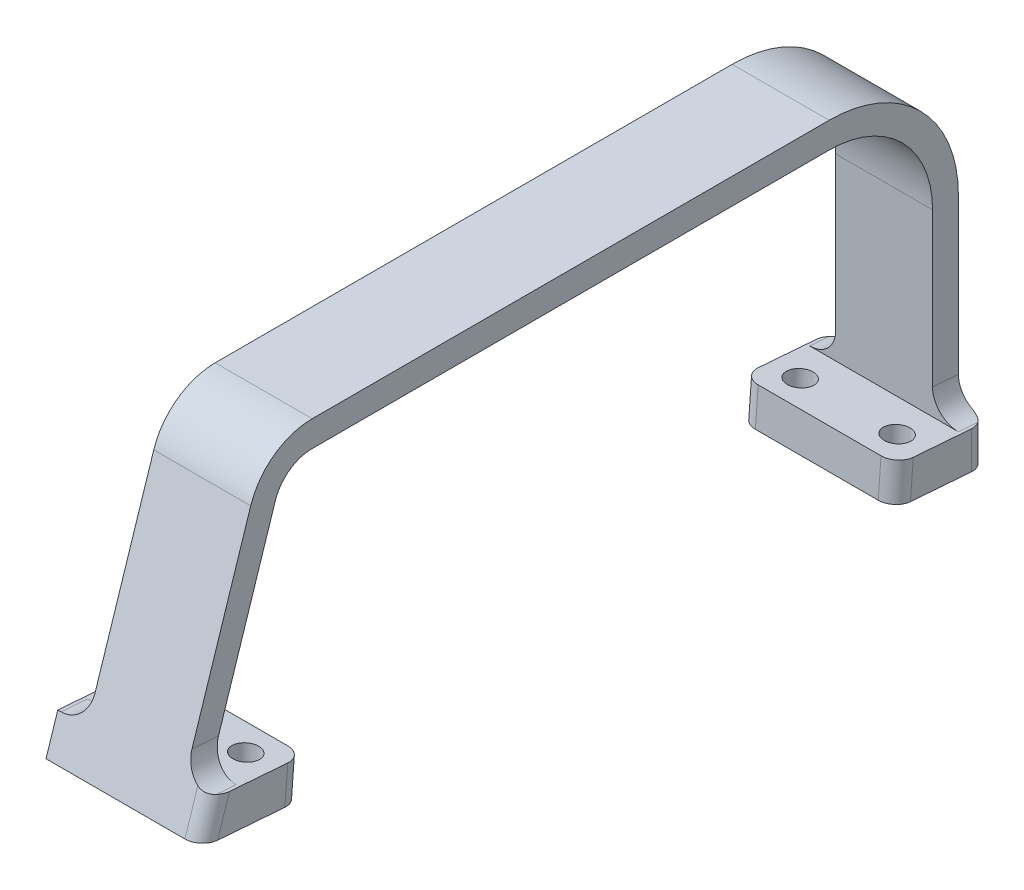
from build123d import *

# Parameters (mm, degrees)
BOSS_EXTRUDE1_DEPTH = 7.5
BOSS_EXTRUDE3_DEPTH = 12
FILLET1_R           = 2.5
FILLET2_R           = 4
CUT_EXTRUDE1_REACH  = 333.875
SKETCH5_R           = 2.0000000000001186
SKETCH5_R_2         = 2.0000000000001266
SKETCH5_R_3         = 2.0000000000001346


with BuildPart() as part:
    # Sketch1 → Boss-Extrude1 (new, symmetric)
    with BuildSketch(Plane(origin=(249.7714193313032, 90.19789758644944, 68.85838392138058), x_dir=(-1.36e-15, 0, -1), z_dir=(1, 1.23e-15, -1.36e-15))):
        with BuildLine():
            Line((276.40733700705005, 27.058032303601674), (280.40733700705005, 26.750876980739832))
            Line((280.40733700705005, 26.750876980739832), (280.40733700705005, 54.805859741005065))
            ThreePointArc((280.40733700705005, 54.80585974100506), (274.549472630781, 68.947995364736), (260.40733700705005, 74.80585974100505))
            Line((260.40733700705005, 74.80585974100507), (180.40733700705002, 74.80585974100505))
            ThreePointArc((180.40733700705002, 74.80585974100504), (174.52666621732683, 72.89398134388023), (170.89462091629855, 67.88940195358433))
            Line((170.89462091629855, 67.88940195358433), (158.7191888589005, 30.328239997775782))
            Line((158.7191888589005, 30.32823999777578), (162.8219643315265, 30.01319266654476))
            Line((162.8219643315265, 30.013192666544757), (174.69970735259915, 66.65598506855262))
            ThreePointArc((174.69970735259915, 66.65598506855262), (176.8789345332161, 69.65873270273018), (180.40733700705002, 70.80585974100507))
            Line((180.40733700705002, 70.80585974100505), (260.40733700705005, 70.80585974100507))
            ThreePointArc((260.40733700705005, 70.80585974100507), (271.7210455060348, 66.1195682399898), (276.40733700705005, 54.80585974100506))
            Line((276.40733700705005, 54.80585974100506), (276.40733700705005, 27.058032303601674))
        make_face()
    extrude(amount=BOSS_EXTRUDE1_DEPTH, both=True)

    # Sketch1_4 → Boss-Extrude3 (add, symmetric)
    with BuildSketch(Plane(origin=(249.7714193313032, 90.19789758644944, 68.85838392138058), x_dir=(-1.36e-15, 0, -1), z_dir=(1, 1.23e-15, -1.36e-15))):
        Polygon((174.61655820891, 34.87442718512688), (164.64591108515557, 35.64006151923646), (162.8219643315265, 30.01319266654476), (174.17631846679706, 29.14130508896809), align=None)
        Polygon((164.64591108515557, 35.64006151923646), (160.5431356125297, 35.95510885046747), (158.7191888589005, 30.328239997775782), (162.8219643315265, 30.01319266654476), align=None)
        Polygon((276.40733700705005, 21.291104712411546), (280.40733700705005, 20.983949389549675), (280.40733700705005, 26.750876980739832), (276.40733700705005, 27.058032303601674), align=None)
        Polygon((265.9964501411826, 22.090544541552422), (276.40733700705005, 21.291104712411546), (276.40733700705005, 27.058032303601674), (266.4366898832956, 27.823666637711245), align=None)
    extrude(amount=BOSS_EXTRUDE3_DEPTH, both=True)

    # Fillet1
    fillet1_edges = [part.edges().sort_by_distance(p)[0] for p in [
        (237.77141933130292, 122.20576372349691, -105.53805441647292),
        (261.7714193313029, 122.20576372349694, -105.53805441647295),
        (261.7714193313029, 123.33957201057109, -90.77277831433453),
        (261.7714193313028, 115.1550031760813, -197.35818609085857),
        (237.7714193313028, 114.06531077159418, -211.54895308566944),
        (261.7714193313028, 114.06531077159421, -211.5489530856695),
        (237.7714193313028, 115.15500317608127, -197.3581860908585),
    ]]
    fillet(fillet1_edges, radius=FILLET1_R)

    # Fillet2
    fillet2_edges = [part.edges().sort_by_distance(p)[0] for p in [
        (257.271419331303, 125.9954827713014, -93.73613942746209),
        (242.27141933130298, 125.99548277130137, -93.73613942746206),
        (242.2714193313028, 117.10235222862019, -209.54895308566944),
        (257.2714193313028, 117.10235222862022, -209.5489530856695),
    ]]
    fillet(fillet2_edges, radius=FILLET2_R)

    # Sketch5 → Cut-Extrude1 (cut, up to next)
    with BuildSketch(Plane(origin=(-1.7714e-13, 132.41259718729538, -10.16780851001), x_dir=(1, 1.33e-15, -1e-16), z_dir=(-1.3338661735596055e-15, 0.9970647123754437, -0.07656343341095512)), mode=Mode.PRIVATE) as cut_extrude1_sk1:
        with Locations(Location((242.271419331303, 192.46222063201034, 0), (0, 0, 270))):
            Circle(SKETCH5_R)
    cut_extrude1_tool1 = extrude(cut_extrude1_sk1.sketch, amount=-CUT_EXTRUDE1_REACH, mode=Mode.PRIVATE) & part.part
    # Sketch5 → Cut-Extrude1 (cut, up to next)
    with BuildSketch(Plane(origin=(-1.7714e-13, 132.41259718729538, -10.16780851001), x_dir=(1, 1.33e-15, -1e-16), z_dir=(-1.3338661735596055e-15, 0.9970647123754437, -0.07656343341095512)), mode=Mode.PRIVATE) as cut_extrude1_sk2:
        with Locations(Location((257.2714193313028, 192.46222063201034, 0), (0, 0, 270))):
            Circle(SKETCH5_R_2)
    cut_extrude1_tool2 = extrude(cut_extrude1_sk2.sketch, amount=-CUT_EXTRUDE1_REACH, mode=Mode.PRIVATE) & part.part
    # Sketch5 → Cut-Extrude1 (cut, up to next)
    with BuildSketch(Plane(origin=(-1.7714e-13, 132.41259718729538, -10.16780851001), x_dir=(1, 1.33e-15, -1e-16), z_dir=(-1.3338661735596055e-15, 0.9970647123754437, -0.07656343341095512)), mode=Mode.PRIVATE) as cut_extrude1_sk3:
        with Locations(Location((242.27141933130304, 91.37177701814517, 0), (0, 0, 270))):
            Circle(SKETCH5_R_3)
    cut_extrude1_tool3 = extrude(cut_extrude1_sk3.sketch, amount=-CUT_EXTRUDE1_REACH, mode=Mode.PRIVATE) & part.part
    # Sketch5 → Cut-Extrude1 (cut, up to next)
    with BuildSketch(Plane(origin=(-1.7714e-13, 132.41259718729538, -10.16780851001), x_dir=(1, 1.33e-15, -1e-16), z_dir=(-1.3338661735596055e-15, 0.9970647123754437, -0.07656343341095512)), mode=Mode.PRIVATE) as cut_extrude1_sk4:
        with Locations(Location((257.27141933130287, 91.37177701814517, 0), (0, 0, 270))):
            Circle(SKETCH5_R_3)
    cut_extrude1_tool4 = extrude(cut_extrude1_sk4.sketch, amount=-CUT_EXTRUDE1_REACH, mode=Mode.PRIVATE) & part.part
    add(cut_extrude1_tool1.solids().sort_by_distance((242.271419, 117.677029, -202.065097))[0], mode=Mode.SUBTRACT)
    add(cut_extrude1_tool2.solids().sort_by_distance((257.271419, 117.677029, -202.065097))[0], mode=Mode.SUBTRACT)
    add(cut_extrude1_tool3.solids().sort_by_distance((242.271419, 125.41686, -101.271383))[0], mode=Mode.SUBTRACT)
    add(cut_extrude1_tool4.solids().sort_by_distance((257.271419, 125.41686, -101.271383))[0], mode=Mode.SUBTRACT)


solid = part.part
